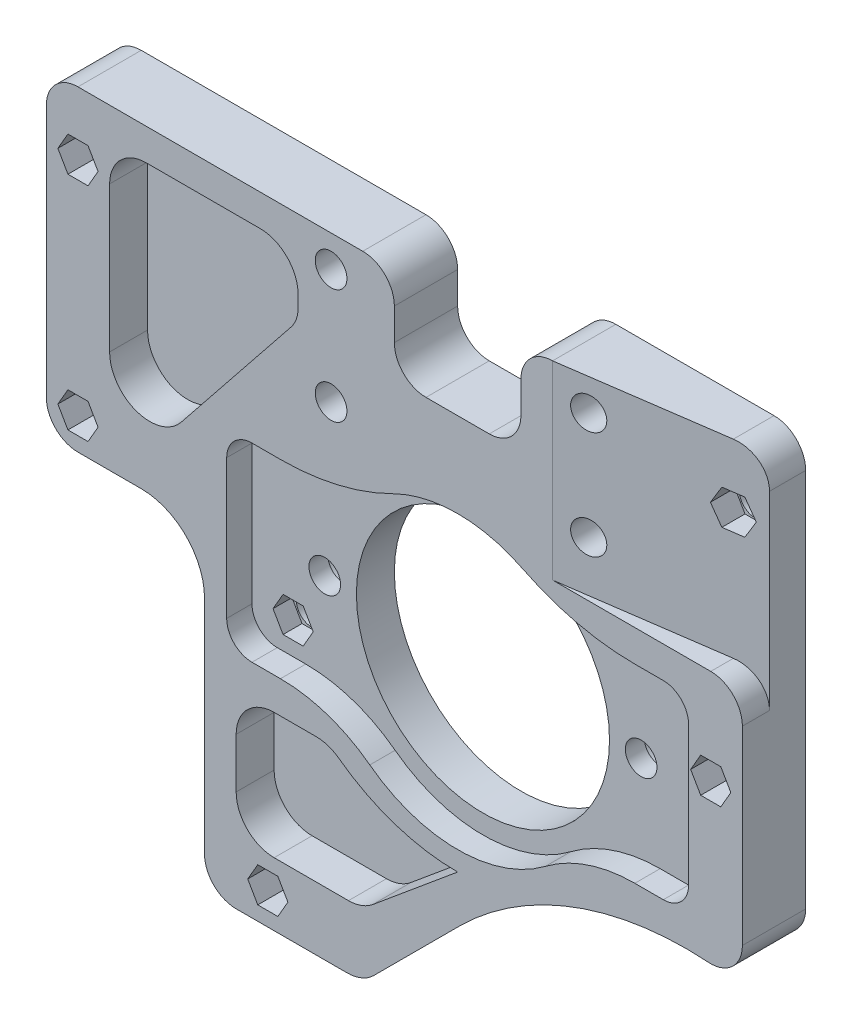
from build123d import *

# Parameters (mm, degrees)
FIGURE_EXTRUDE_DEPTH      = 10
SKETCH2_R                 = 20
SKETCH2_R_2               = 2.5
ALL_5MM_HOLES_DEPTH       = 93.736184955
ANGLED_PLANE_CUT_DEPTH    = 30
ANGLED_PLANE_FILLET_R     = 5
TRIANGULAR_CUT_DEPTH      = 6
MIDDLE_CIRCULAR_CUT_DEPTH = 4
CUT_EXTRUDE12_DEPTH       = 6
SKETCH7_R                 = 3.75
CUT_EXTRUDE13_DEPTH       = 3
CUT_EXTRUDE14_DEPTH       = 5
CUT_EXTRUDE15_DEPTH       = 7
CUT_EXTRUDE17_DEPTH       = 7


with BuildPart() as part:
    # Sketch1 → Figure Extrude (new body)
    with BuildSketch(Plane.XY):
        with BuildLine():
            Line((0, 30), (-45, 30))
            ThreePointArc((-45, 30), (-48.535533906, 28.535533906), (-50, 25))
            Line((-50, 25), (-50, -15))
            ThreePointArc((-50, -15), (-48.535533906, -18.535533906), (-45, -20))
            Line((-45, -20), (-35, -20))
            ThreePointArc((-35, -20), (-27.928932188, -22.928932188), (-25, -30))
            Line((-25, -30), (-25, -65))
            ThreePointArc((-25, -65), (-23.535533906, -68.535533906), (-20, -70))
            Line((-20, -70), (-2.48528, -70))
            ThreePointArc((-2.48528, -70), (-0.189179406, -69.543277195), (1.757360687, -68.242640687))
            Line((1.757360687, -68.242640687), (15.280716751, -54.719284623))
            ThreePointArc((15.280716751, -54.719284623), (33.367897146, -43.085414566), (54.651065241, -40))
            ThreePointArc((54.651065241, -40), (58.409935938, -38.669011007), (60, -35.012190407))
            Line((60, -35.012190407), (60, 25))
            ThreePointArc((60, 25), (58.535533906, 28.535533906), (55, 30))
            Line((55, 30), (30, 30))
            ThreePointArc((30, 30), (26.464466094, 28.535533906), (25, 25))
            Line((25, 25), (25, 20))
            ThreePointArc((25, 20), (23.535533906, 16.464466094), (20, 15))
            Line((20, 15), (10, 15))
            ThreePointArc((10, 15), (6.464466094, 16.464466094), (5, 20))
            Line((5, 20), (5, 25))
            ThreePointArc((5, 25), (3.535533906, 28.535533906), (0, 30))
        make_face()
    extrude(amount=FIGURE_EXTRUDE_DEPTH)

    # Sketch2 → All 5mm Holes (cut, through all)
    with BuildSketch(Plane.XY):
        with Locations((15, -21.4)):
            Circle(SKETCH2_R)
        with Locations((55, 20)):
            Circle(SKETCH2_R_2)
        with Locations((55, -15)):
            Circle(SKETCH2_R_2)
        with Locations((-45, 20)):
            Circle(SKETCH2_R_2)
        with Locations((-45, -15)):
            Circle(SKETCH2_R_2)
        with Locations((35, 25)):
            Circle(SKETCH2_R_2)
        with Locations((35, 7.98621)):
            Circle(SKETCH2_R_2)
        with Locations((-5, 25)):
            Circle(SKETCH2_R_2)
        with Locations((-5, 6.85613)):
            Circle(SKETCH2_R_2)
        with Locations((-15, -30)):
            Circle(SKETCH2_R_2)
        with Locations((-15, -65)):
            Circle(SKETCH2_R_2)
        with Locations((-10, -21.4)):
            Circle(SKETCH2_R_2)
        with Locations((40, -21.4)):
            Circle(SKETCH2_R_2)
    extrude(amount=ALL_5MM_HOLES_DEPTH, mode=Mode.SUBTRACT)

    # Sketch3 → Angled Plane Cut (cut)
    with BuildSketch(Plane(origin=(0, 30, 0), x_dir=(1, 0, 0), z_dir=(0, 1, 0))):
        Polygon((30, -10), (60, -5.714340401), (60, -10), align=None)
    extrude(amount=-ANGLED_PLANE_CUT_DEPTH, mode=Mode.SUBTRACT)

    # Angled Plane Fillet
    angled_plane_fillet_edges = [part.edges().sort_by_distance(p)[0] for p in [
        (60, 0, 7.8571702),
    ]]
    fillet(angled_plane_fillet_edges, radius=ANGLED_PLANE_FILLET_R)

    # Sketch4 → Triangular cut (cut)
    with BuildSketch(Plane.XY.offset(10)):
        with BuildLine():
            Line((-34.217521015, 25), (-16.217521015, 25))
            ThreePointArc((-16.217521015, 25), (-11.974880328, 23.242640687), (-10.217521015, 19))
            Line((-10.217521015, 19), (-10.217521015, 17.10468))
            ThreePointArc((-10.217521015, 17.10468), (-10.499794454, 15.447216646), (-11.31479, 13.976623119))
            Line((-11.31479, 13.976623119), (-28.69474373, -7.74817))
            ThreePointArc((-28.69474373, -7.74817), (-35.753124005, -9.772794597), (-40, -3.782478985))
            Line((-40, -3.782478985), (-40, 19.217521015))
            ThreePointArc((-40, 19.217521015), (-38.306351117, 23.306351117), (-34.217521015, 25))
        make_face()
    extrude(amount=-TRIANGULAR_CUT_DEPTH, mode=Mode.SUBTRACT)

    # Sketch5 → Middle Circular Cut (cut)
    with BuildSketch(Plane.XY.offset(10)):
        with BuildLine():
            Line((-21.5, -9), (-21.5, -31))
            ThreePointArc((-21.5, -31), (-20.328427125, -33.828427125), (-17.5, -35))
            Line((-17.5, -35), (-13, -35))
            ThreePointArc((-13, -35), (-5.552074466, -36.216817559), (1.121326058, -39.740730891))
            ThreePointArc((1.121326058, -39.740730891), (15, -44.4), (28.878673942, -39.740730891))
            ThreePointArc((28.878673942, -39.740730891), (35.552074466, -36.216817559), (43, -35))
            Line((43, -35), (47.5, -35))
            ThreePointArc((47.5, -35), (50.328427125, -33.828427125), (51.5, -31))
            Line((51.5, -31), (51.5, -9))
            ThreePointArc((51.5, -9), (50.328427125, -6.171572875), (47.5, -5))
            Line((47.5, -5), (43, -5))
            ThreePointArc((43, -5), (33.893145617, -3.941200412), (25.272125284, -0.821286674))
            ThreePointArc((25.272125284, -0.821286674), (15, 1.6), (4.727874716, -0.821286674))
            ThreePointArc((4.727874716, -0.821286674), (-3.893145617, -3.941200412), (-13, -5))
            Line((-13, -5), (-17.5, -5))
            ThreePointArc((-17.5, -5), (-20.328427125, -6.171572875), (-21.5, -9))
        make_face()
    extrude(amount=-MIDDLE_CIRCULAR_CUT_DEPTH, mode=Mode.SUBTRACT)

    # Sketch6 → Cut-Extrude12 (cut)
    with BuildSketch(Plane.XY.offset(10)):
        with BuildLine():
            Line((-20, -54), (-20, -46.1088))
            ThreePointArc((-20, -46.1088), (-18.242640687, -41.866159313), (-14, -40.1088))
            Line((-14, -40.1088), (-7.34446, -40.1088))
            ThreePointArc((-7.34446, -40.1088), (-5.468840073, -40.409497421), (-3.781218172, -41.281450036))
            ThreePointArc((-3.781218172, -41.281450036), (5.113938727, -45.877358228), (15, -47.462281209))
            Line((15, -47.462281209), (1.587090544, -58.613720541))
            ThreePointArc((1.587090544, -58.613720541), (-0.209415261, -59.642797323), (-2.24873828, -60))
            Line((-2.24873828, -60), (-14, -60))
            ThreePointArc((-14, -60), (-18.242640687, -58.242640687), (-20, -54))
        make_face()
    extrude(amount=-CUT_EXTRUDE12_DEPTH, mode=Mode.SUBTRACT)

    # Sketch7 → Cut-Extrude13 (cut)
    with BuildSketch(Plane(origin=(0, 0, 0), x_dir=(-1, 0, 0), z_dir=(0, 0, -1))):
        with Locations((-40, -21.4)):
            Circle(SKETCH7_R)
        with Locations((10, -21.4)):
            Circle(SKETCH7_R)
    extrude(amount=-CUT_EXTRUDE13_DEPTH, mode=Mode.SUBTRACT)

    # Sketch8 → Cut-Extrude14 (cut)
    with BuildSketch(Plane(origin=(0, 0, 0), x_dir=(-1, 0, 0), z_dir=(0, 0, -1))):
        Polygon((-33.41229, 27.749994388), (-36.58771, 27.749994388), (-38.17542, 25), (-36.58771, 22.250005612), (-33.41229, 22.250005612), (-31.82458, 25), align=None)
        Polygon((-33.41229, 10.736204388), (-36.58771, 10.736204388), (-38.17542, 7.98621), (-36.58771, 5.236215612), (-33.41229, 5.236215612), (-31.82458, 7.98621), align=None)
        Polygon((3.41229, 9.606124388), (1.82458, 6.85613), (3.41229, 4.106135612), (6.58771, 4.106135612), (8.17542, 6.85613), (6.58771, 9.606124388), align=None)
        Polygon((3.41229, 27.749994388), (1.82458, 25), (3.41229, 22.250005612), (6.58771, 22.250005612), (8.17542, 25), (6.58771, 27.749994388), align=None)
    extrude(amount=-CUT_EXTRUDE14_DEPTH, mode=Mode.SUBTRACT)

    # Sketch9 → Cut-Extrude15 (cut)
    with BuildSketch(Plane.XY.offset(10)):
        Polygon((-43.41229, 22.749994388), (-46.58771, 22.749994388), (-48.17542, 20), (-46.58771, 17.250005612), (-43.41229, 17.250005612), (-41.82458, 20), align=None)
        Polygon((-41.82458, -15), (-43.41229, -12.250005612), (-46.58771, -12.250005612), (-48.17542, -15), (-46.58771, -17.749994388), (-43.41229, -17.749994388), align=None)
        Polygon((-11.82458, -65), (-13.41229, -62.250005612), (-16.58771, -62.250005612), (-18.17542, -65), (-16.58771, -67.749994388), (-13.41229, -67.749994388), align=None)
        Polygon((58.17542, -15), (56.58771, -12.250005612), (53.41229, -12.250005612), (51.82458, -15), (53.41229, -17.749994388), (56.58771, -17.749994388), align=None)
        Polygon((58.17542, 20), (56.58771, 22.749994388), (53.41229, 22.749994388), (51.82458, 20), (53.41229, 17.250005612), (56.58771, 17.250005612), align=None)
    extrude(amount=-CUT_EXTRUDE15_DEPTH, mode=Mode.SUBTRACT)

    # Sketch9_4 → Cut-Extrude17 (cut)
    with BuildSketch(Plane.XY.offset(10)):
        Polygon((-11.82458, -30), (-13.41229, -27.250005612), (-16.58771, -27.250005612), (-18.17542, -30), (-16.58771, -32.749994388), (-13.41229, -32.749994388), align=None)
    extrude(amount=-CUT_EXTRUDE17_DEPTH, mode=Mode.SUBTRACT)


solid = part.part
